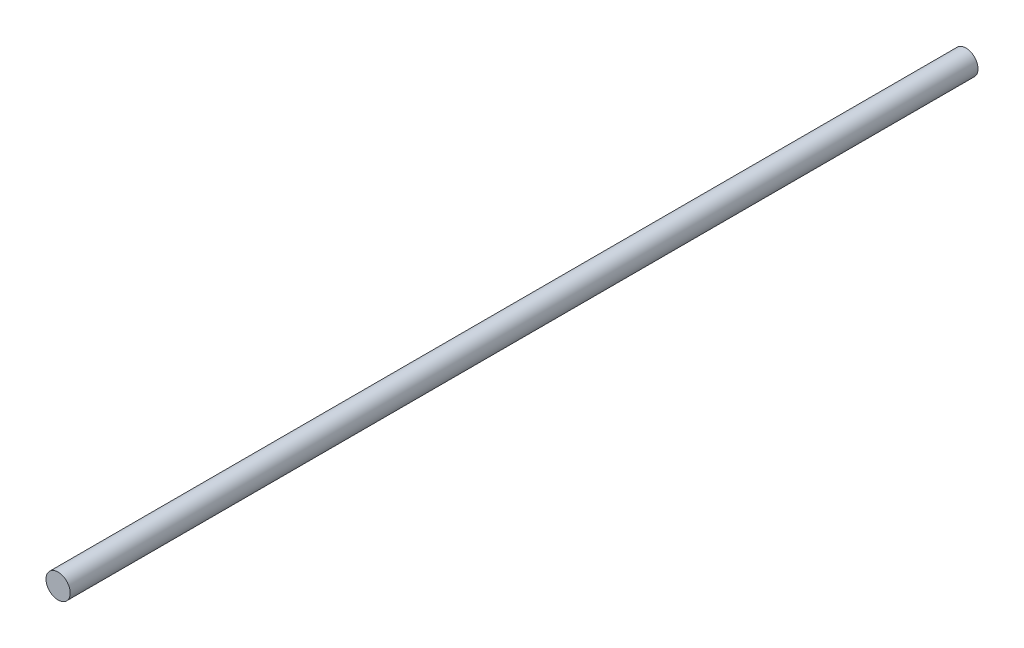
from build123d import *

# Parameters (mm, degrees)
SKETCH1_R           = 2
BOSS_EXTRUDE1_DEPTH = 150


with BuildPart() as part:
    # Sketch1 → Boss-Extrude1 (new body)
    with BuildSketch(Plane.XY):
        Circle(SKETCH1_R)
    extrude(amount=BOSS_EXTRUDE1_DEPTH)


solid = part.part
